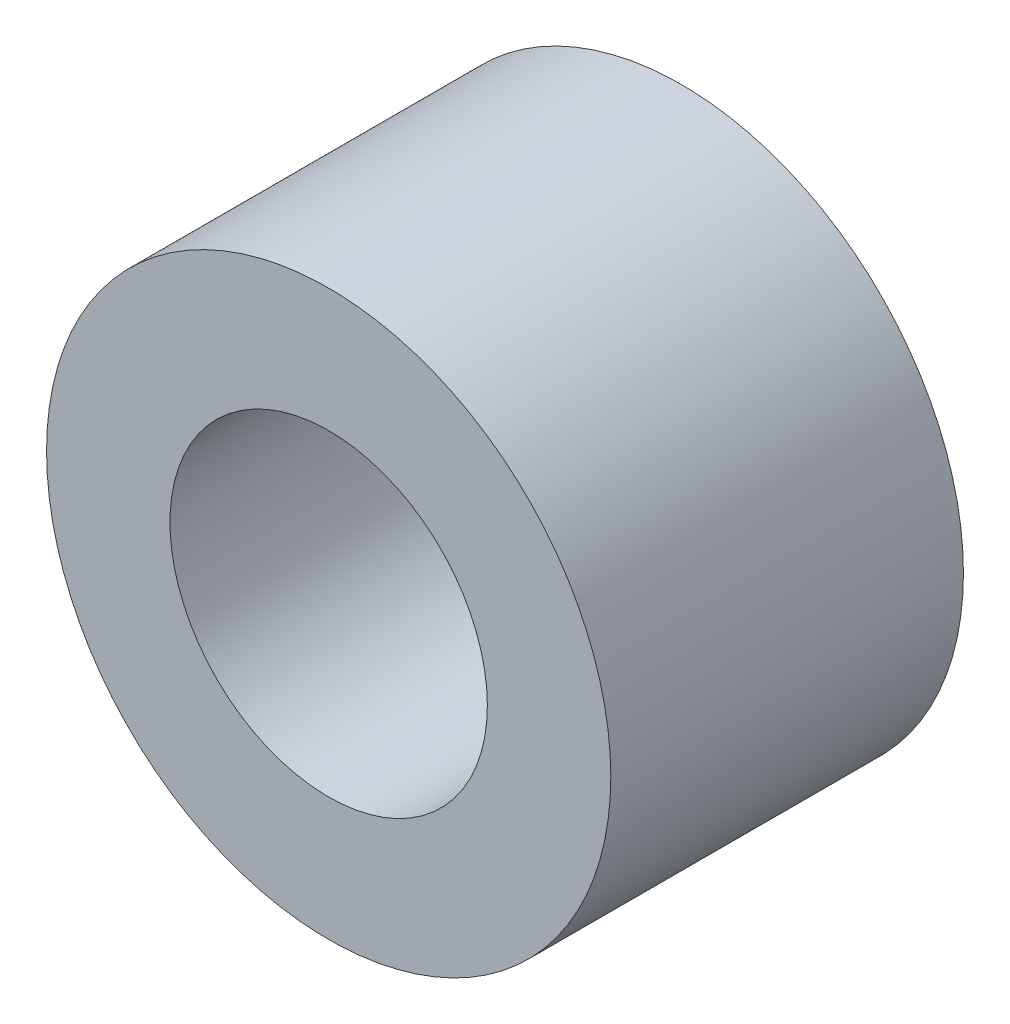
from build123d import *

# Parameters (mm, degrees)
SKETCH1_R           = 4
SKETCH1_R_2         = 2.25
BOSS_EXTRUDE1_DEPTH = 5


with BuildPart() as part:
    # Sketch1 → Boss-Extrude1 (new body)
    with BuildSketch(Plane.XY):
        Circle(SKETCH1_R)
        Circle(SKETCH1_R_2, mode=Mode.SUBTRACT)
    extrude(amount=BOSS_EXTRUDE1_DEPTH)


solid = part.part
